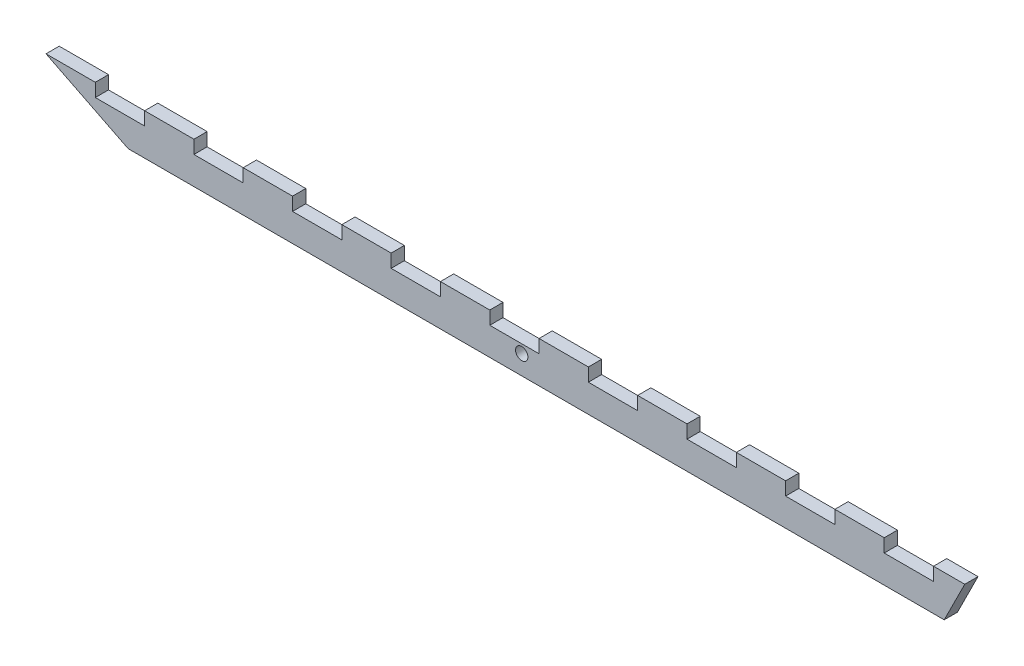
from build123d import *

# Parameters (mm, degrees)
SKETCH1_R           = 1.5
BOSS_EXTRUDE1_DEPTH = 1.61
SKETCH2_W           = 12
SKETCH2_H           = 3.22
CUT_EXTRUDE1_DEPTH  = 3.22
LPATTERN1_COUNT     = 9
LPATTERN1_PITCH     = 24


with BuildPart() as part:
    # Sketch1 → Boss-Extrude1 (new body, symmetric)
    with BuildSketch(Plane.XY):
        Polygon((-95.775442885, -4.703941319), (-115.775442885, 5.296058681), (107.831354865, 5.296058681), (102.831354865, -4.703941319), align=None)
        Circle(SKETCH1_R, mode=Mode.SUBTRACT)
    extrude(amount=BOSS_EXTRUDE1_DEPTH, both=True)

    # Sketch2 → Cut-Extrude1 (cut)
    with BuildSketch(Plane.XY.offset(1.61)):
        with Locations((-97.775442885, 3.686058681)):
            Rectangle(SKETCH2_W, SKETCH2_H)
    cut_extrude1 = extrude(amount=-CUT_EXTRUDE1_DEPTH, mode=Mode.SUBTRACT)

    # LPattern1: Cut-Extrude1 ×9
    with Locations(*[(i * LPATTERN1_PITCH, 0, 0) for i in range(1, LPATTERN1_COUNT)]):
        add(cut_extrude1, mode=Mode.SUBTRACT)


solid = part.part
